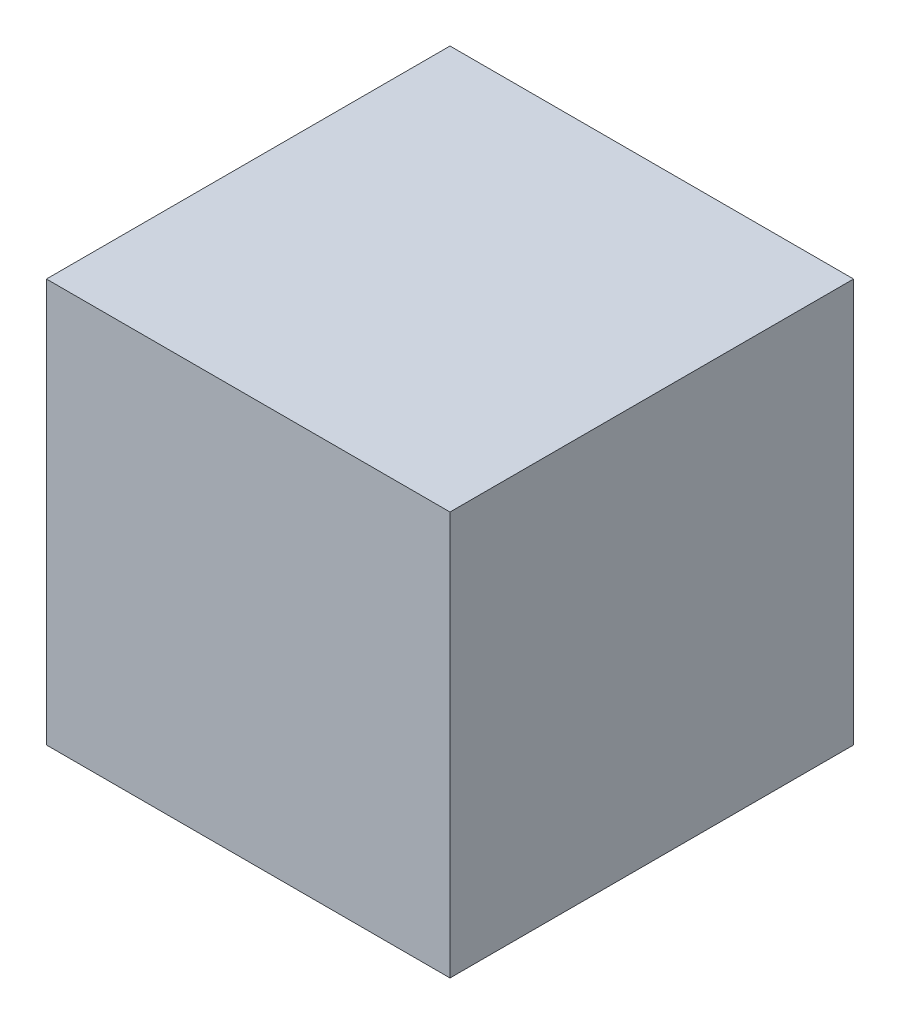
from build123d import *

# Parameters (mm, degrees)
SKETCH1_W           = 914.4
SKETCH1_H           = 914.4
BOSS_EXTRUDE1_DEPTH = 914.4


with BuildPart() as part:
    # Sketch1 → Boss-Extrude1 (new body)
    with BuildSketch(Plane(origin=(0, 0, 0), x_dir=(1, 0, 0), z_dir=(0, 1, 0))):
        with Locations((457.2, -457.2)):
            Rectangle(SKETCH1_W, SKETCH1_H)
    extrude(amount=BOSS_EXTRUDE1_DEPTH)


solid = part.part
